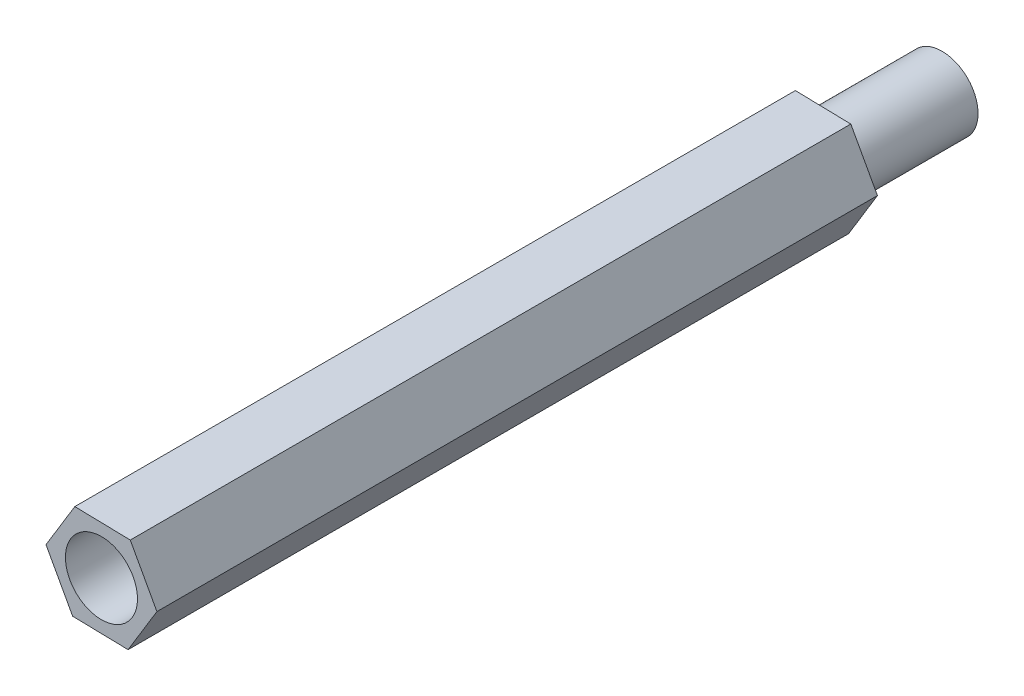
from build123d import *

# Parameters (mm, degrees)
EXTRUDE_2_DEPTH     = 30
SKETCH_5_R          = 1.498354352
EXTRUDE_3_DEPTH     = 5
SKETCH_6_R          = 1.5
CUT_EXTRUDE_1_DEPTH = 5


with BuildPart() as part:
    # 草图4 → 凸台-拉伸2 (new body)
    with BuildSketch(Plane.XY):
        Polygon((1.108848503, -2.025780919), (2.30880199, -0.052599487), (1.199953487, 1.973181432), (-1.108848503, 2.025780919), (-2.30880199, 0.052599487), (-1.199953487, -1.973181432), align=None)
    extrude(amount=EXTRUDE_2_DEPTH)

    # 草图5 → 凸台-拉伸3 (add)
    with BuildSketch(Plane(origin=(0, 0, 0), x_dir=(-1, 0, 0), z_dir=(0, 0, -1))):
        Circle(SKETCH_5_R)
    extrude(amount=EXTRUDE_3_DEPTH)

    # 草图6 → 切除-拉伸1 (cut)
    with BuildSketch(Plane.XY.offset(30)):
        Circle(SKETCH_6_R)
    extrude(amount=-CUT_EXTRUDE_1_DEPTH, mode=Mode.SUBTRACT)


solid = part.part
